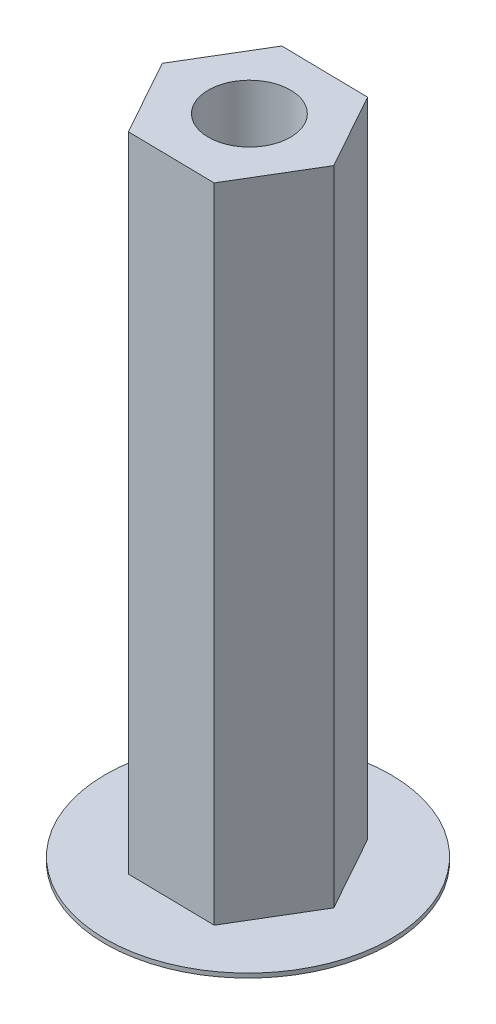
from build123d import *

# Parameters (mm, degrees)
SKETCH1_R           = 1.9
BOSS_EXTRUDE1_DEPTH = 30
SKETCH3_R           = 6.607376419
SKETCH3_R_2         = 1.965008769
BOSS_EXTRUDE2_DEPTH = 0.2


with BuildPart() as part:
    # Sketch1 → Boss-Extrude1 (new body)
    with BuildSketch(Plane(origin=(0, 0, 0), x_dir=(1, 0, 0), z_dir=(0, 1, 0))):
        Polygon((1.964165255, -3.532051555), (4.040929001, -0.065008769), (2.076763746, 3.467042785), (-1.964165255, 3.532051555), (-4.040929001, 0.065008769), (-2.076763746, -3.467042785), align=None)
        with Locations((0, 0.065008769)):
            Circle(SKETCH1_R, mode=Mode.SUBTRACT)
    extrude(amount=BOSS_EXTRUDE1_DEPTH)

    # Sketch3 → Boss-Extrude2 (add)
    with BuildSketch(Plane(origin=(0, 0, 0), x_dir=(-1, 0, 0), z_dir=(0, -1, 0))):
        Circle(SKETCH3_R)
        Circle(SKETCH3_R_2, mode=Mode.SUBTRACT)
    extrude(amount=-BOSS_EXTRUDE2_DEPTH)


solid = part.part
